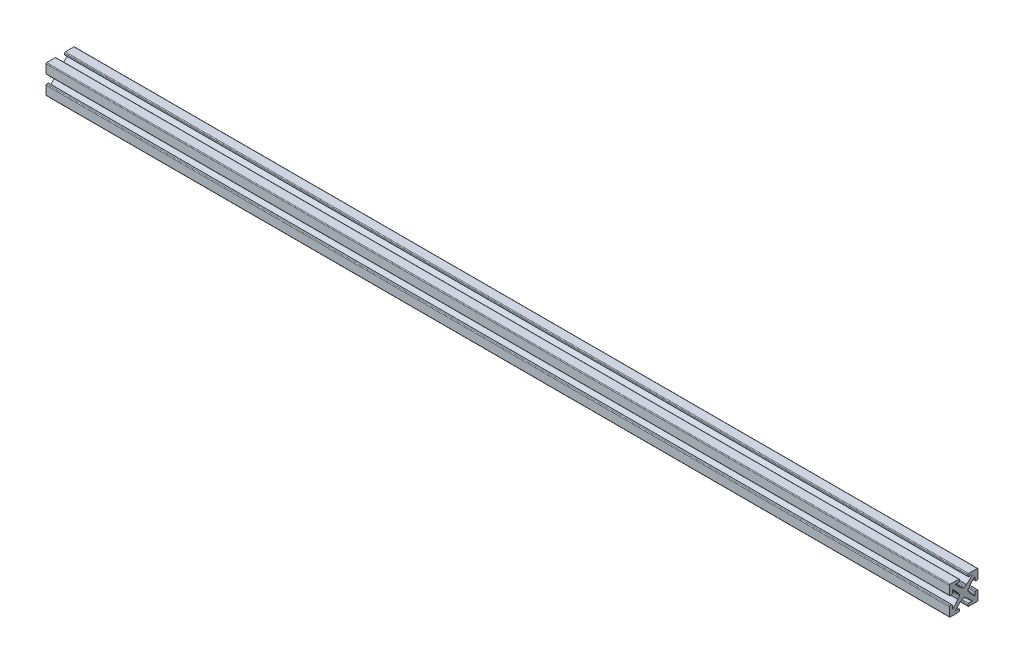
from build123d import *

# Parameters (mm, degrees)
BOSS_EXTRU_1_DEPTH = 316.5


with BuildPart() as part:
    # Sketch1 → Boss.-Extru.1 (new body)
    with BuildSketch(Plane(origin=(0, 0, 0), x_dir=(0, 0, -1), z_dir=(1, 0, 0))):
        with BuildLine():
            Line((-0.2413, 1.4986), (0.2413, 1.4986))
            ThreePointArc((0.2413, 1.4986), (0.420905122, 1.572994878), (0.4953, 1.7526))
            ThreePointArc((0.4953, 1.7526), (0.569694878, 1.932205122), (0.7493, 2.0066))
            Line((0.7493, 2.0066), (0.889923986, 2.0066))
            ThreePointArc((0.889923986, 2.0066), (0.983516259, 2.024471886), (1.063937899, 2.075572548))
            Line((1.063937899, 2.075572548), (2.890793, 3.793686274))
            ThreePointArc((2.890793, 3.793686274), (2.921850101, 3.932996137), (2.803786044, 4.0132))
            Line((2.803786044, 4.0132), (1.7526, 4.0132))
            ThreePointArc((1.7526, 4.0132), (1.572994878, 4.087594878), (1.4986, 4.2672))
            Line((1.4986, 4.2672), (1.4986, 4.7498))
            ThreePointArc((1.4986, 4.7498), (1.572994878, 4.929405122), (1.7526, 5.0038))
            Line((1.7526, 5.0038), (4.7498, 5.0038))
            ThreePointArc((4.7498, 5.0038), (4.929405122, 4.929405122), (5.0038, 4.7498))
            Line((5.0038, 4.7498), (5.0038, 1.7526))
            ThreePointArc((5.0038, 1.7526), (4.929405122, 1.572994878), (4.7498, 1.4986))
            Line((4.7498, 1.4986), (4.2672, 1.4986))
            ThreePointArc((4.2672, 1.4986), (4.087594878, 1.572994878), (4.0132, 1.7526))
            Line((4.0132, 1.7526), (4.0132, 2.803786044))
            ThreePointArc((4.0132, 2.803786044), (3.932996137, 2.921850101), (3.793686274, 2.890793))
            Line((3.793686274, 2.890793), (2.075572548, 1.063937899))
            ThreePointArc((2.075572548, 1.063937899), (2.024471886, 0.983516259), (2.0066, 0.889923986))
            Line((2.0066, 0.889923986), (2.0066, 0.7493))
            ThreePointArc((2.0066, 0.7493), (1.932205122, 0.569694878), (1.7526, 0.4953))
            ThreePointArc((1.7526, 0.4953), (1.572994878, 0.420905122), (1.4986, 0.2413))
            Line((1.4986, 0.2413), (1.4986, -0.2413))
            ThreePointArc((1.4986, -0.2413), (1.572994878, -0.420905122), (1.7526, -0.4953))
            ThreePointArc((1.7526, -0.4953), (1.932205122, -0.569694878), (2.0066, -0.7493))
            Line((2.0066, -0.7493), (2.0066, -0.889923986))
            ThreePointArc((2.0066, -0.889923986), (2.024471886, -0.983516259), (2.075572548, -1.063937899))
            Line((2.075572548, -1.063937899), (3.793686274, -2.890793))
            ThreePointArc((3.793686274, -2.890793), (3.932996137, -2.921850101), (4.0132, -2.803786044))
            Line((4.0132, -2.803786044), (4.0132, -1.7526))
            ThreePointArc((4.0132, -1.7526), (4.087594878, -1.572994878), (4.2672, -1.4986))
            Line((4.2672, -1.4986), (4.7498, -1.4986))
            ThreePointArc((4.7498, -1.4986), (4.929405122, -1.572994878), (5.0038, -1.7526))
            Line((5.0038, -1.7526), (5.0038, -4.7498))
            ThreePointArc((5.0038, -4.7498), (4.929405122, -4.929405122), (4.7498, -5.0038))
            Line((4.7498, -5.0038), (1.7526, -5.0038))
            ThreePointArc((1.7526, -5.0038), (1.572994878, -4.929405122), (1.4986, -4.7498))
            Line((1.4986, -4.7498), (1.4986, -4.2672))
            ThreePointArc((1.4986, -4.2672), (1.572994878, -4.087594878), (1.7526, -4.0132))
            Line((1.7526, -4.0132), (2.803786044, -4.0132))
            ThreePointArc((2.803786044, -4.0132), (2.921850101, -3.932996137), (2.890793, -3.793686274))
            Line((2.890793, -3.793686274), (1.063937899, -2.075572548))
            ThreePointArc((1.063937899, -2.075572548), (0.983516259, -2.024471886), (0.889923986, -2.0066))
            Line((0.889923986, -2.0066), (0.7493, -2.0066))
            ThreePointArc((0.7493, -2.0066), (0.569694878, -1.932205122), (0.4953, -1.7526))
            ThreePointArc((0.4953, -1.7526), (0.420905122, -1.572994878), (0.2413, -1.4986))
            Line((0.2413, -1.4986), (-0.2413, -1.4986))
            ThreePointArc((-0.2413, -1.4986), (-0.420905122, -1.572994878), (-0.4953, -1.7526))
            ThreePointArc((-0.4953, -1.7526), (-0.569694878, -1.932205122), (-0.7493, -2.0066))
            Line((-0.7493, -2.0066), (-0.889923986, -2.0066))
            ThreePointArc((-0.889923986, -2.0066), (-0.983516259, -2.024471886), (-1.063937899, -2.075572548))
            Line((-1.063937899, -2.075572548), (-2.890793, -3.793686274))
            ThreePointArc((-2.890793, -3.793686274), (-2.921850101, -3.932996137), (-2.803786044, -4.0132))
            Line((-2.803786044, -4.0132), (-1.7526, -4.0132))
            ThreePointArc((-1.7526, -4.0132), (-1.572994878, -4.087594878), (-1.4986, -4.2672))
            Line((-1.4986, -4.2672), (-1.4986, -4.7498))
            ThreePointArc((-1.4986, -4.7498), (-1.572994878, -4.929405122), (-1.7526, -5.0038))
            Line((-1.7526, -5.0038), (-4.7498, -5.0038))
            ThreePointArc((-4.7498, -5.0038), (-4.929405122, -4.929405122), (-5.0038, -4.7498))
            Line((-5.0038, -4.7498), (-5.0038, -1.7526))
            ThreePointArc((-5.0038, -1.7526), (-4.929405122, -1.572994878), (-4.7498, -1.4986))
            Line((-4.7498, -1.4986), (-4.2672, -1.4986))
            ThreePointArc((-4.2672, -1.4986), (-4.087594878, -1.572994878), (-4.0132, -1.7526))
            Line((-4.0132, -1.7526), (-4.0132, -2.803786044))
            ThreePointArc((-4.0132, -2.803786044), (-3.932996137, -2.921850101), (-3.793686274, -2.890793))
            Line((-3.793686274, -2.890793), (-2.075572548, -1.063937899))
            ThreePointArc((-2.075572548, -1.063937899), (-2.024471886, -0.983516259), (-2.0066, -0.889923986))
            Line((-2.0066, -0.889923986), (-2.0066, -0.7493))
            ThreePointArc((-2.0066, -0.7493), (-1.932205122, -0.569694878), (-1.7526, -0.4953))
            ThreePointArc((-1.7526, -0.4953), (-1.572994878, -0.420905122), (-1.4986, -0.2413))
            Line((-1.4986, -0.2413), (-1.4986, 0.2413))
            ThreePointArc((-1.4986, 0.2413), (-1.572994878, 0.420905122), (-1.7526, 0.4953))
            ThreePointArc((-1.7526, 0.4953), (-1.932205122, 0.569694878), (-2.0066, 0.7493))
            Line((-2.0066, 0.7493), (-2.0066, 0.889923986))
            ThreePointArc((-2.0066, 0.889923986), (-2.024471886, 0.983516259), (-2.075572548, 1.063937899))
            Line((-2.075572548, 1.063937899), (-3.793686274, 2.890793))
            ThreePointArc((-3.793686274, 2.890793), (-3.932996137, 2.921850101), (-4.0132, 2.803786044))
            Line((-4.0132, 2.803786044), (-4.0132, 1.7526))
            ThreePointArc((-4.0132, 1.7526), (-4.087594878, 1.572994878), (-4.2672, 1.4986))
            Line((-4.2672, 1.4986), (-4.7498, 1.4986))
            ThreePointArc((-4.7498, 1.4986), (-4.929405122, 1.572994878), (-5.0038, 1.7526))
            Line((-5.0038, 1.7526), (-5.0038, 4.7498))
            ThreePointArc((-5.0038, 4.7498), (-4.929405122, 4.929405122), (-4.7498, 5.0038))
            Line((-4.7498, 5.0038), (-1.7526, 5.0038))
            ThreePointArc((-1.7526, 5.0038), (-1.572994878, 4.929405122), (-1.4986, 4.7498))
            Line((-1.4986, 4.7498), (-1.4986, 4.2672))
            ThreePointArc((-1.4986, 4.2672), (-1.572994878, 4.087594878), (-1.7526, 4.0132))
            Line((-1.7526, 4.0132), (-2.803786044, 4.0132))
            ThreePointArc((-2.803786044, 4.0132), (-2.921850101, 3.932996137), (-2.890793, 3.793686274))
            Line((-2.890793, 3.793686274), (-1.063937899, 2.075572548))
            ThreePointArc((-1.063937899, 2.075572548), (-0.983516259, 2.024471886), (-0.889923986, 2.0066))
            Line((-0.889923986, 2.0066), (-0.7493, 2.0066))
            ThreePointArc((-0.7493, 2.0066), (-0.569694878, 1.932205122), (-0.4953, 1.7526))
            ThreePointArc((-0.4953, 1.7526), (-0.420905122, 1.572994878), (-0.2413, 1.4986))
        make_face()
    extrude(amount=BOSS_EXTRU_1_DEPTH)


solid = part.part
